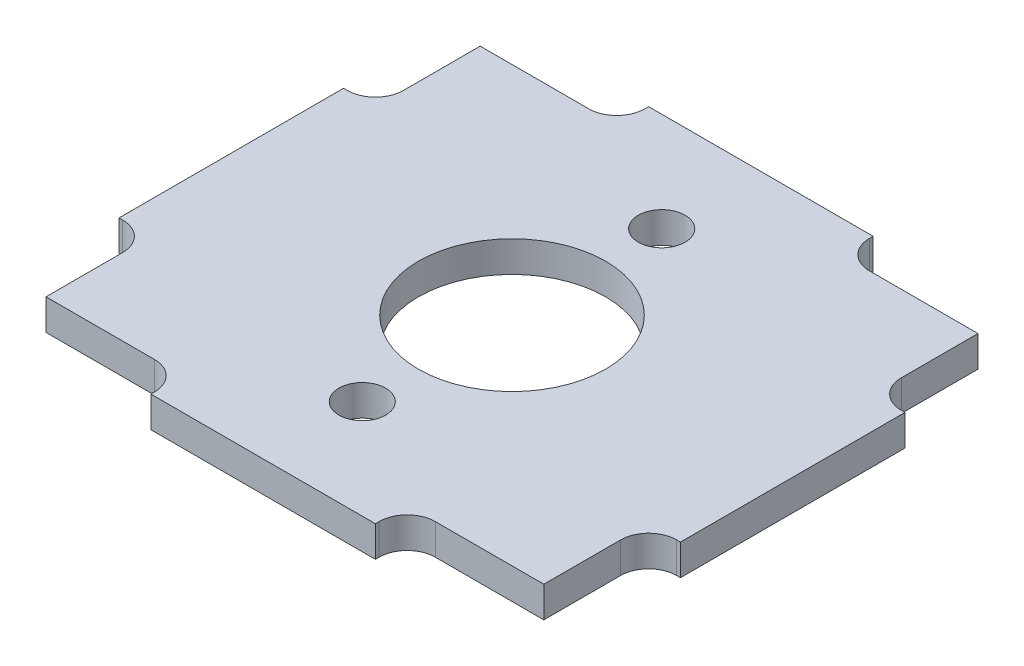
from build123d import *

# Parameters (mm, degrees)
SKIZZE1_R                       = 1.25
SKIZZE1_R_2                     = 5
AUFSATZ_LINEAR_AUSTRAGEN1_DEPTH = 0.825
VERRUNDUNG1_R                   = 1.5


with BuildPart() as part:
    # Skizze1 → Aufsatz-Linear austragen1 (new body, symmetric)
    with BuildSketch(Plane(origin=(0, 0, 0), x_dir=(1, 0, 0), z_dir=(0, 1, 0))):
        Polygon((-13.3, -6), (-13.3, -11.6), (-6, -11.6), (-6, -13.3), (6, -13.3), (6, -11.6), (13.3, -11.6), (13.3, -6), (15, -6), (15, 6), (13.3, 6), (13.3, 11.6), (6, 11.6), (6, 13.3), (-6, 13.3), (-6, 11.6), (-13.3, 11.6), (-13.3, 6), (-15, 6), (-15, -6), align=None)
        with Locations((0, -8)):
            Circle(SKIZZE1_R, mode=Mode.SUBTRACT)
        with Locations((0, 8)):
            Circle(SKIZZE1_R, mode=Mode.SUBTRACT)
        Circle(SKIZZE1_R_2, mode=Mode.SUBTRACT)
    extrude(amount=AUFSATZ_LINEAR_AUSTRAGEN1_DEPTH, both=True)

    # Verrundung1
    verrundung1_edges = [part.edges().sort_by_distance(p)[0] for p in [
        (-6, 0, 11.6),
        (-13.3, 0, 6),
        (-13.3, 0, -6),
        (-6, 0, -11.6),
        (6, 0, -11.6),
        (13.3, 0, -6),
        (13.3, 0, 6),
        (6, 0, 11.6),
    ]]
    fillet(verrundung1_edges, radius=VERRUNDUNG1_R)


solid = part.part
